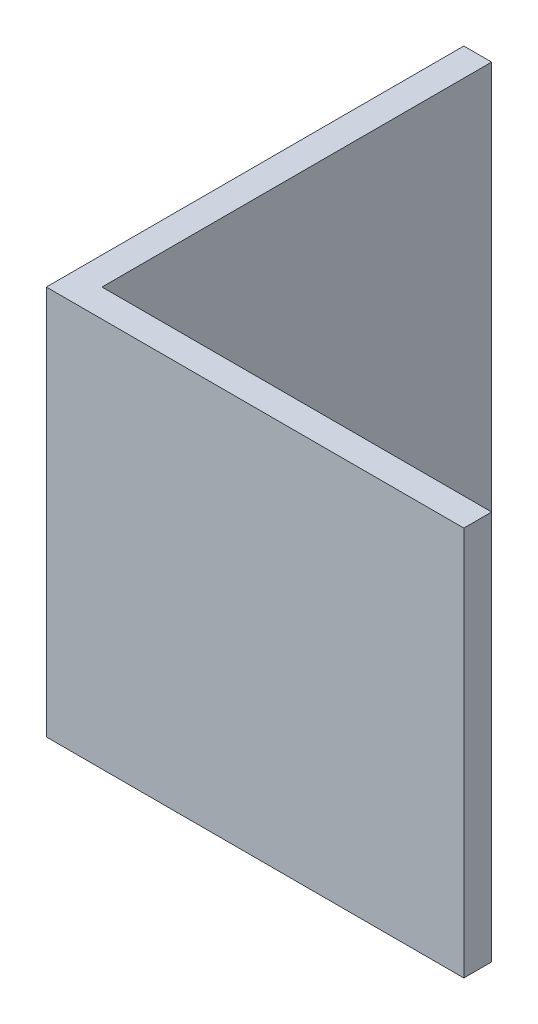
from build123d import *

# Parameters (mm, degrees)
EXTRUDE_1_DEPTH = 14


with BuildPart() as part:
    # Эскиз1 → Бобышка-Вытянуть1 (new body)
    with BuildSketch(Plane(origin=(0, 0, 0), x_dir=(1, 0, 0), z_dir=(0, 1, 0))):
        Polygon((0, 0), (0, 15), (1, 15), (1, 1), (15, 1), (15, 0), align=None)
    extrude(amount=EXTRUDE_1_DEPTH)


solid = part.part
